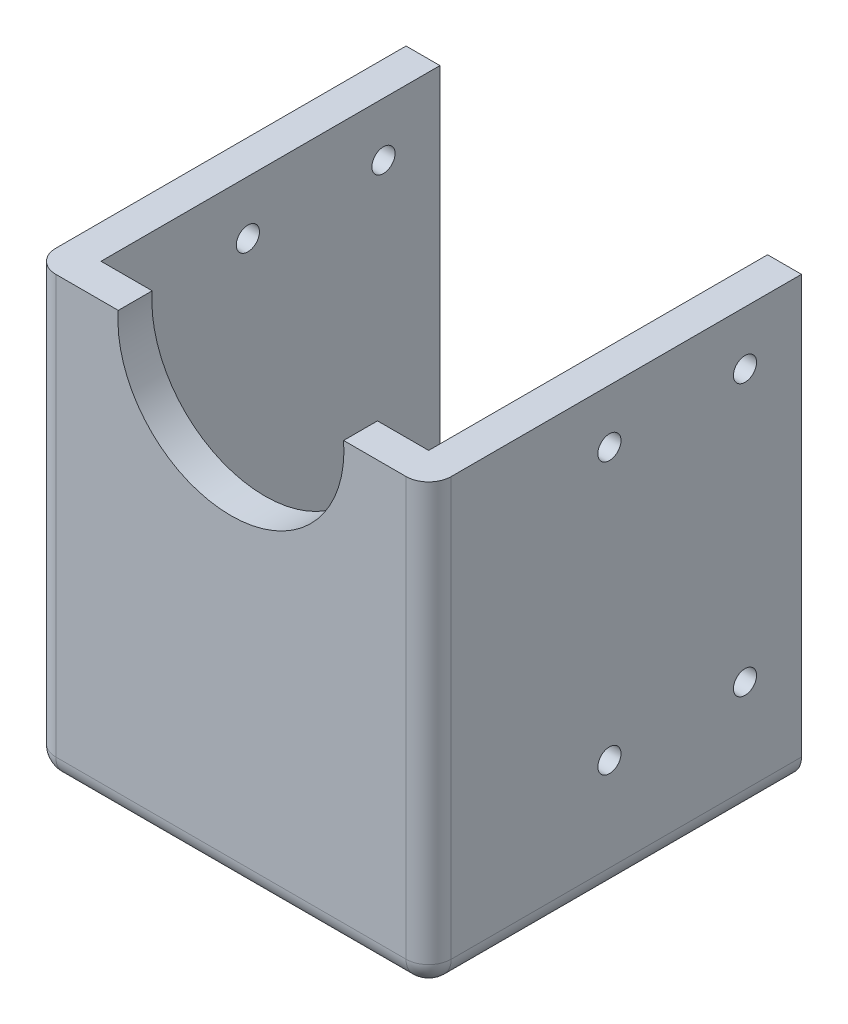
from build123d import *

# Parameters (mm, degrees)
EXTRUDE_1_DEPTH     = 3
EXTRUDE_2_DEPTH     = 30
SKETCH_3_R          = 1.025
CUT_EXTRUDE_1_DEPTH = 43
SKETCH_4_R          = 1.025
CUT_EXTRUDE_2_DEPTH = 3
FILLET_1_R          = 2


with BuildPart() as part:
    # 스케치2 → 보스-돌출1 (new body)
    with BuildSketch(Plane.XY):
        with BuildLine():
            Line((17.75, 0.75), (10.221835338, 0.75))
            ThreePointArc((10.221835338, 0.75), (0.25, -10), (-9.721835338, 0.75))
            Line((-9.721835338, 0.75), (-17.25, 0.75))
            Line((-17.25, 0.75), (-17.25, -38.25))
            Line((-17.25, -38.25), (17.75, -38.25))
            Line((17.75, -38.25), (17.75, 0.75))
        make_face()
    extrude(amount=EXTRUDE_1_DEPTH)

    # 스케치2<6> → 보스-돌출2 (add)
    with BuildSketch(Plane.XY):
        Polygon((14.75, 0.75), (14.75, -35.25), (-14.25, -35.25), (-14.25, 0.75), (-17.25, 0.75), (-17.25, -38.25), (17.75, -38.25), (17.75, 0.75), align=None)
    extrude(amount=-EXTRUDE_2_DEPTH)

    # 스케치3 → 컷-돌출1 (cut)
    with BuildSketch(Plane(origin=(17.75, 0, 0), x_dir=(0, 0, -1), z_dir=(1, 0, 0))):
        with Locations((25, -4)):
            Circle(SKETCH_3_R)
        with Locations((13, -4)):
            Circle(SKETCH_3_R)
        with Locations((25, -28)):
            Circle(SKETCH_3_R)
        with Locations((13, -28)):
            Circle(SKETCH_3_R)
    extrude(amount=-CUT_EXTRUDE_1_DEPTH, mode=Mode.SUBTRACT)

    # 스케치4 → 컷-돌출2 (cut)
    with BuildSketch(Plane.XZ.offset(38.25)):
        with Locations((8.25, -25)):
            Circle(SKETCH_4_R)
        with Locations((-7.75, -25)):
            Circle(SKETCH_4_R)
        with Locations((-7.75, -13)):
            Circle(SKETCH_4_R)
        with Locations((8.25, -13)):
            Circle(SKETCH_4_R)
    extrude(amount=-CUT_EXTRUDE_2_DEPTH, mode=Mode.SUBTRACT)

    # 필렛1
    fillet_1_edges = [part.edges().sort_by_distance(p)[0] for p in [
        (-17.25, -18.75, 3),
        (-17.25, -38.25, -13.5),
        (17.75, -38.25, -13.5),
        (0.25, -38.25, 3),
        (17.75, -18.75, 3),
    ]]
    fillet(fillet_1_edges, radius=FILLET_1_R)


solid = part.part
